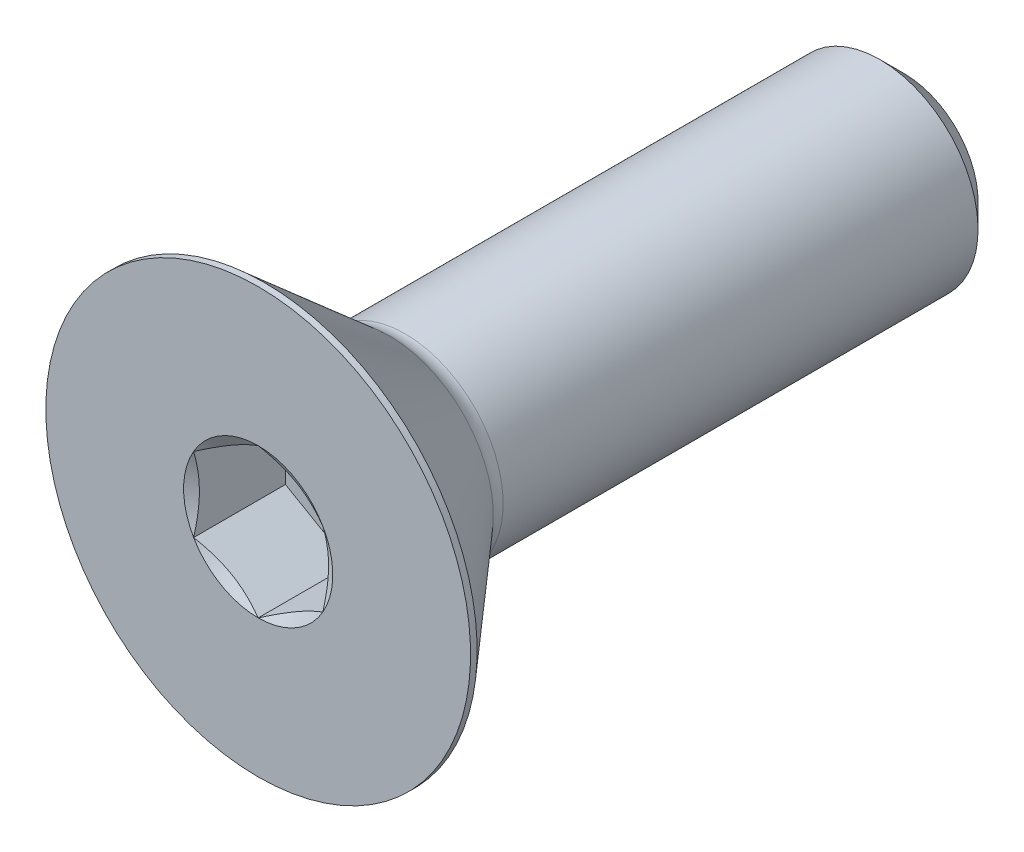
from build123d import *

# Parameters (mm, degrees)
SKETCH1_W          = 15.875
SKETCH1_H          = 2.413
CHAMFER1_SIZE      = 0.5953125
CUT_EXTRUDE2_DEPTH = 2.25806


with BuildPart() as part:
    # Sketch1 → Revolve1 (revolve)
    with BuildSketch(Plane(origin=(0, 0, 0), x_dir=(0, 0, -1), z_dir=(1, 0, 0))):
        with Locations((7.9375, 1.2065)):
            Rectangle(SKETCH1_W, SKETCH1_H)
    revolve(axis=Axis((0, 0, -15.875), (0, 0, 1)))

    # Chamfer1
    chamfer1_edges = [part.edges().sort_by_distance(p)[0] for p in [
        (0, -2.413, -15.875),
    ]]
    chamfer(chamfer1_edges, length=CHAMFER1_SIZE)

    # Sketch7 → Revolve2 (revolve)
    with BuildSketch(Plane(origin=(0, 0, 0), x_dir=(0, 0, -1), z_dir=(1, 0, 0)), mode=Mode.PRIVATE) as revolve2_sk:
        with BuildLine():
            Line((0, 5.2197), (0.16129, 5.2197))
            Line((0.16129, 5.2197), (3.2258, 2.555762099))
            ThreePointArc((3.2258, 2.555762099), (3.403809493, 2.44985758), (3.607634579, 2.413))
            Line((3.607634579, 2.413), (3.607634579, 0))
            Line((3.607634579, 0), (0, 0))
            Line((0, 0), (0, 5.2197))
        make_face()
    revolve(revolve2_sk.sketch.rotate(Axis((0, 0, 0), (0, 0, -1)), 180), axis=Axis((0, 0, 0), (0, 0, -1)))

    # Sketch5 → Cut-Extrude2 (cut)
    with BuildSketch(Plane.XY):
        Polygon((0, 1.833087105), (-1.5875, 0.916543552), (-1.5875, -0.916543552), (0, -1.833087105), (1.5875, -0.916543552), (1.5875, 0.916543552), align=None)
    extrude(amount=-CUT_EXTRUDE2_DEPTH, mode=Mode.SUBTRACT)

    # Cut-Extrude3 cone 1 section (through the dimple's axis) → Cut-Extrude3 (revolve, cut)
    with BuildSketch(Plane(origin=(0, 0, 0), x_dir=(0, -1, 0), z_dir=(1, 0, 0))):
        Polygon((0, 0), (1.833087105, 0), (0, 1.058333333), align=None)
    revolve(axis=Axis((0, 0, 0), (0, 0, -1)), mode=Mode.SUBTRACT)


solid = part.part
